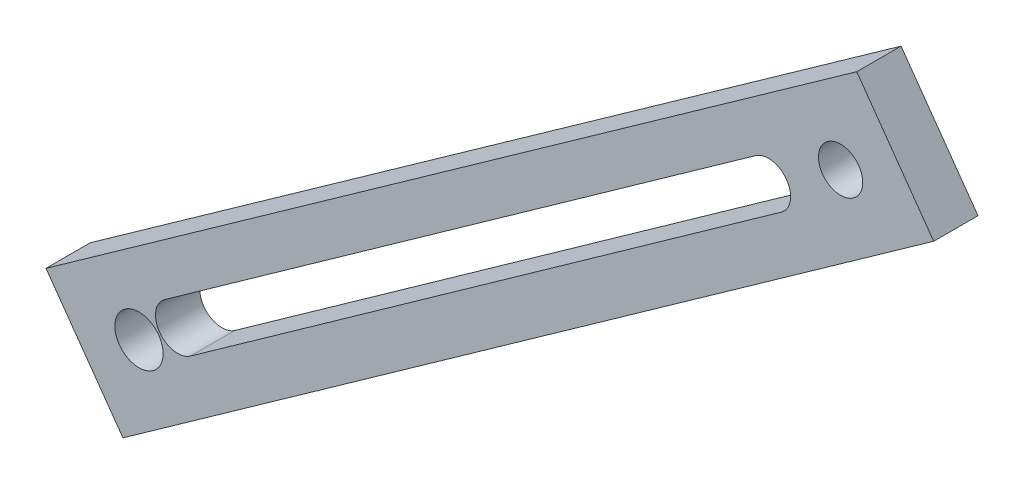
from build123d import *

# Parameters (mm, degrees)
BOSS_EXTRUDE1_DEPTH     = 2.54
SKETCH2_R               = 1.384838531
SKETCH2_R_2             = 1.27
CUT_EXTRUDE2_DEPTH      = 2.54
CUT_EXTRUDE4_DEPTH      = 7.62
CUT_EXTRUDE4_DEPTH_BACK = 10.16


with BuildPart() as part:
    # Sketch1 → Boss-Extrude1 (new body)
    with BuildSketch(Plane.XY):
        Polygon((-71.208440462, -3.308212961), (-24.728354348, 29.69264818), (-29.139739371, 35.905866523), (-75.619825485, 2.905005382), align=None)
    extrude(amount=BOSS_EXTRUDE1_DEPTH)

    # Sketch2 → Cut-Extrude2 (cut)
    with BuildSketch(Plane.XY.offset(2.54)):
        with Locations((-70.288529602, 2.017574604)):
            Circle(SKETCH2_R)
        with Locations((-30.065513702, 30.575915893)):
            Circle(SKETCH2_R_2)
    extrude(amount=-CUT_EXTRUDE2_DEPTH, mode=Mode.SUBTRACT)

    # Sketch3 → Cut-Extrude4 (cut, two sides)
    with BuildSketch(Plane(origin=(0, 0, 0), x_dir=(-1, 0, 0), z_dir=(0, 0, -1))) as cut_extrude4_sk:
        with BuildLine():
            Line((67.337713358, 2.689008108), (33.465419067, 26.769994698))
            ThreePointArc((33.465419067, 26.769994698), (33.166213405, 28.540948106), (34.937166813, 28.840153767))
            Line((34.937166813, 28.840153767), (68.809461104, 4.759167177))
            ThreePointArc((68.809461104, 4.759167177), (69.108666765, 2.988213769), (67.337713358, 2.689008108))
        make_face()
    extrude(amount=CUT_EXTRUDE4_DEPTH, mode=Mode.SUBTRACT)
    extrude(cut_extrude4_sk.sketch, amount=-CUT_EXTRUDE4_DEPTH_BACK, mode=Mode.SUBTRACT)


solid = part.part
